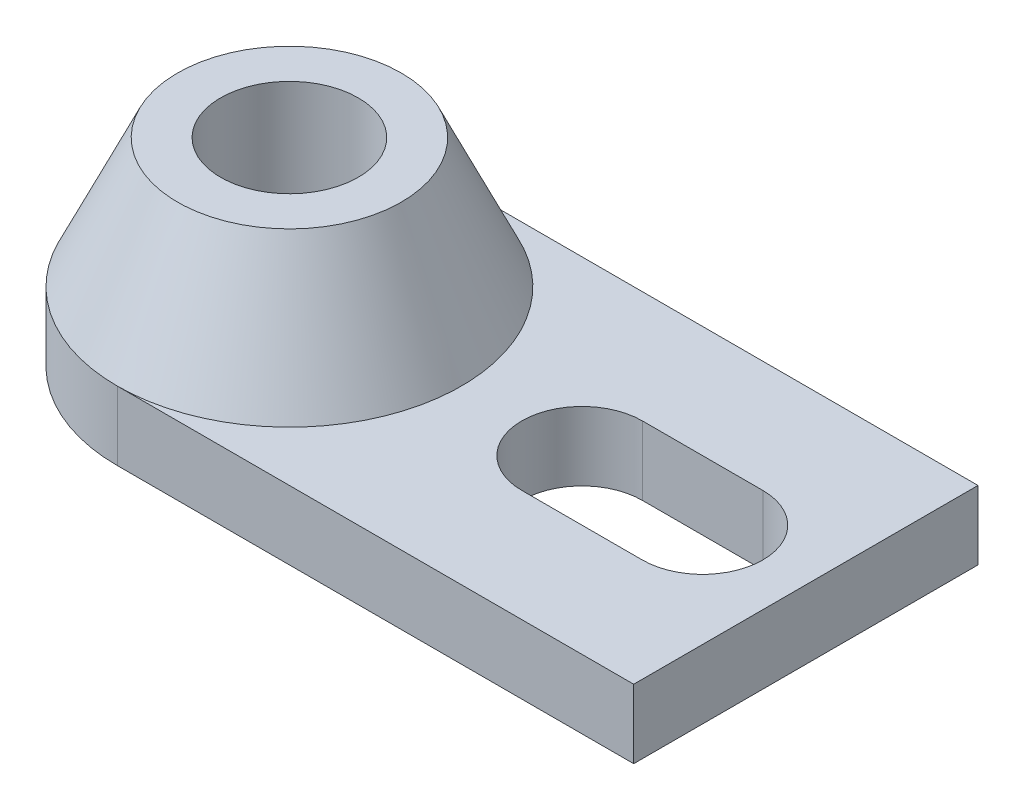
from build123d import *

# Parameters (mm, degrees)
BOSS_EXTRUDE2_DEPTH = 8


with BuildPart() as part:
    # Sketch2 → Boss-Extrude2 (new body)
    with BuildSketch(Plane(origin=(0, 0, 0), x_dir=(1, 0, 0), z_dir=(0, 1, 0))):
        with BuildLine():
            Line((0, -20), (-60, -20))
            ThreePointArc((-60, -20), (-80, 0), (-60, 20))
            Line((-60, 20), (0, 20))
            Line((0, 20), (0, -20))
        make_face()
        with BuildLine():
            Line((-26, 7), (-12, 7))
            ThreePointArc((-12, 7), (-5, 0), (-12, -7))
            Line((-12, -7), (-26, -7))
            ThreePointArc((-26, -7), (-33, 0), (-26, 7))
        make_face(mode=Mode.SUBTRACT)
    extrude(amount=BOSS_EXTRUDE2_DEPTH)

    # Sketch4 → Revolve4 (revolve)
    with BuildSketch(Plane.XY, mode=Mode.PRIVATE) as revolve4_sk:
        Polygon((-68, 8), (-68, 23), (-73, 23), (-80, 8), align=None)
    revolve(revolve4_sk.sketch.rotate(Axis((-60, 8, 0), (0, 1, 0)), 270), axis=Axis((-60, 8, 0), (0, 1, 0)))  # turned: the seam where the file's is


solid = part.part
